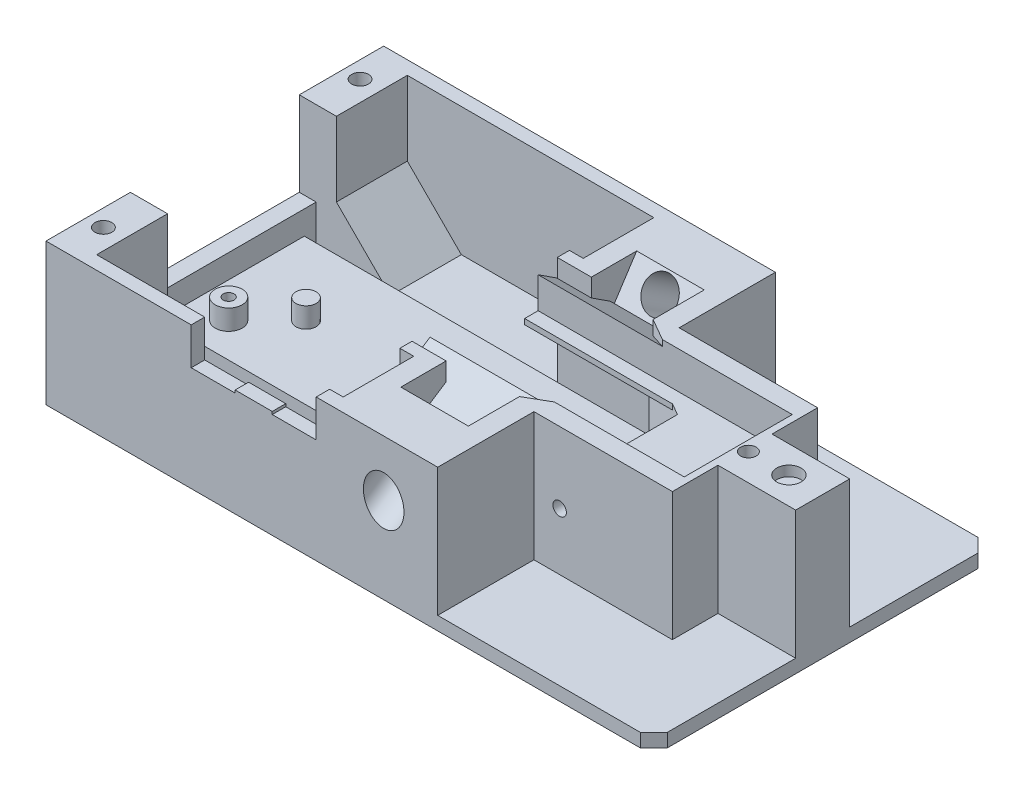
from build123d import *

# Parameters (mm, degrees)
SKETCH1_W           = 90
SKETCH1_H           = 50
BOSS_EXTRUDE1_DEPTH = 21
CUT_EXTRUDE1_DEPTH  = 16
SKETCH4_R           = 2.5
CUT_EXTRUDE2_DEPTH  = 63.626624678
SKETCH5_W           = 10
SKETCH5_H           = 6.2
CUT_EXTRUDE3_DEPTH  = 19
SKETCH6_R           = 3
CUT_EXTRUDE4_DEPTH  = 20
SKETCH11_R          = 1.5
BOSS_EXTRUDE3_DEPTH = 3
BOSS_EXTRUDE2_DEPTH = 23.630686795
CUT_EXTRUDE6_DEPTH  = 19
SKETCH17_W          = 16
SKETCH17_H          = 3.2
CUT_EXTRUDE10_DEPTH = 37.549476
SKETCH15_R          = 1.8
CUT_EXTRUDE8_DEPTH  = 1.5
SKETCH16_R          = 1.25
CUT_EXTRUDE9_DEPTH  = 19
CUT_EXTRUDE11_REACH = 23
SKETCH19_R          = 4
CHAMFER1_SIZE       = 8
CHAMFER2_SIZE       = 2
CUT_EXTRUDE12_REACH = 52
SKETCH21_W          = 21.5
SKETCH21_H          = 3
BOSS_EXTRUDE4_DEPTH = 5.5
CUT_EXTRUDE13_REACH = 23
SKETCH23_W          = 37.630686795
SKETCH23_H          = 16
SKETCH25_R          = 1.15
CUT_EXTRUDE14_DEPTH = 10
SKETCH26_R          = 1
CUT_EXTRUDE15_DEPTH = 36.75
SKETCH27_W          = 2.5
SKETCH27_H          = 25
BOSS_EXTRUDE6_DEPTH = 6.5
SKETCH28_W          = 10
SKETCH28_H          = 0.8
CUT_EXTRUDE16_DEPTH = 4
SKETCH22_R          = 2
SKETCH22_R_2        = 0.8
BOSS_EXTRUDE7_DEPTH = 3


with BuildPart() as part:
    # Sketch1 → Boss-Extrude1 (new body)
    with BuildSketch(Plane(origin=(0, 0, 0), x_dir=(1, 0, 0), z_dir=(0, 1, 0))):
        with Locations((-5, 0)):
            Rectangle(SKETCH1_W, SKETCH1_H)
    extrude(amount=BOSS_EXTRUDE1_DEPTH)

    # Sketch2 → Cut-Extrude1 (cut)
    with BuildSketch(Plane(origin=(0, 21, 0), x_dir=(1, 0, 0), z_dir=(0, 1, 0))):
        Polygon((-44.5, 10.75), (3.5, 10.75), (13.5, 5), (13.5, -5), (3.5, -10.75), (-44.5, -10.75), align=None)
    extrude(amount=-CUT_EXTRUDE1_DEPTH, mode=Mode.SUBTRACT)

    # Sketch4 → Cut-Extrude2 (cut, through all)
    with BuildSketch(Plane(origin=(0, 3.891653574, -38.585684316), x_dir=(1, 0, 0), z_dir=(0, 0.545410535, 0.838169045))):
        Circle(SKETCH4_R)
    cut_extrude2 = extrude(amount=CUT_EXTRUDE2_DEPTH, mode=Mode.SUBTRACT)

    # Sketch5 → Cut-Extrude3 (cut)
    with BuildSketch(Plane(origin=(0, 29, 0), x_dir=(1, 0, 0), z_dir=(0, 0.545410535, 0.838169045))):
        with Locations((0, 0.013708289)):
            Rectangle(SKETCH5_W, SKETCH5_H)
    cut_extrude3 = extrude(amount=-CUT_EXTRUDE3_DEPTH, mode=Mode.SUBTRACT)

    # Sketch6 → Cut-Extrude4 (cut)
    with BuildSketch(Plane(origin=(0, 3.891653574, -38.585684316), x_dir=(1, 0, 0), z_dir=(0, 0.545410535, 0.838169045))):
        Circle(SKETCH6_R)
    cut_extrude4 = extrude(amount=CUT_EXTRUDE4_DEPTH, mode=Mode.SUBTRACT)

    # Sketch11 → Boss-Extrude3 (add)
    with BuildSketch(Plane(origin=(0, 5, 0), x_dir=(1, 0, 0), z_dir=(0, 1, 0))):
        with Locations((-36.5, 0)):
            Circle(SKETCH11_R)
        Polygon((11.3, 6.265), (11.3, -6.265), (13.5, -5), (13.5, 5), align=None)
    extrude(amount=BOSS_EXTRUDE3_DEPTH)

    # Sketch9 → Boss-Extrude2 (add)
    with BuildSketch(Plane.ZY.offset(-13.5)):
        Polygon((-8, 18.7), (-8, 15.5), (-6, 15.5), (-6, 14.7), (-10.75, 13.6), (-11.152370245, 13.6), (-11.152370245, 14.662668332), (-11.152370245, 18.060784345), (-6.635479906, 21), (0, 21), (0, 18.7), align=None)
    boss_extrude2 = extrude(amount=BOSS_EXTRUDE2_DEPTH)

    # Mirror1: Cut-Extrude2, Cut-Extrude3, Cut-Extrude4, Boss-Extrude2 across plane
    add(cut_extrude2.mirror(Plane.XY), mode=Mode.SUBTRACT)
    add(cut_extrude3.mirror(Plane.XY), mode=Mode.SUBTRACT)
    add(cut_extrude4.mirror(Plane.XY), mode=Mode.SUBTRACT)
    add(boss_extrude2.mirror(Plane.XY))

    # Sketch10 → Cut-Extrude6 (cut)
    with BuildSketch(Plane(origin=(0, 21, 0), x_dir=(1, 0, 0), z_dir=(0, 1, 0))):
        Polygon((-44.5, 12.5), (-44.5, 23), (-8, 23), (-8, 12.55), (-10.049475977, 12.55), (-10.049475977, 10.75), (-44.5, 10.75), (-44.5, 0), (-50, 0), (-50, 12.5), align=None)
        Polygon((8, 25), (8, 10.75), (28.5, 10.75), (28.5, 4), (46.328078386, 4), (46.328078386, 30.717572765), (8, 31.044325351), align=None)
    cut_extrude6 = extrude(amount=-CUT_EXTRUDE6_DEPTH, mode=Mode.SUBTRACT)

    # Mirror2: Cut-Extrude6 across plane
    add(cut_extrude6.mirror(Plane.XY), mode=Mode.SUBTRACT)

    # Sketch17 → Cut-Extrude10 (cut)
    with BuildSketch(Plane.ZY.offset(10.049475977)):
        with Locations((0, 17.1)):
            Rectangle(SKETCH17_W, SKETCH17_H)
    extrude(amount=-CUT_EXTRUDE10_DEPTH, mode=Mode.SUBTRACT)

    # Sketch15 → Cut-Extrude8 (cut)
    with BuildSketch(Plane(origin=(0, 21, 0), x_dir=(1, 0, 0), z_dir=(0, 1, 0))):
        with Locations((35, 0)):
            Circle(SKETCH15_R)
    extrude(amount=-CUT_EXTRUDE8_DEPTH, mode=Mode.SUBTRACT)

    # Sketch16 → Cut-Extrude9 (cut)
    with BuildSketch(Plane(origin=(0, 21, 0), x_dir=(1, 0, 0), z_dir=(0, 1, 0))):
        with Locations((-47.5, 19)):
            Circle(SKETCH16_R)
        with Locations((-47.5, -19)):
            Circle(SKETCH16_R)
    extrude(amount=-CUT_EXTRUDE9_DEPTH, mode=Mode.SUBTRACT)

    # Sketch19 → Cut-Extrude11 (cut, up to next)
    with BuildSketch(Plane(origin=(0, 21, 0), x_dir=(1, 0, 0), z_dir=(0, 1, 0)), mode=Mode.PRIVATE) as cut_extrude11_sk1:
        Circle(SKETCH19_R)
    cut_extrude11_tool1 = extrude(cut_extrude11_sk1.sketch, amount=-CUT_EXTRUDE11_REACH, mode=Mode.PRIVATE) & part.part
    add(cut_extrude11_tool1.solids().sort_by_distance((0, 21, 0))[0], mode=Mode.SUBTRACT)

    # Chamfer1
    chamfer1_edges = [part.edges().sort_by_distance(p)[0] for p in [
        (-44.5, 2, -17.75),
        (-44.5, 2, 17.75),
    ]]
    chamfer(chamfer1_edges, length=CHAMFER1_SIZE)

    # Chamfer2
    chamfer2_edges = [part.edges().sort_by_distance(p)[0] for p in [
        (40, 1, -25),
        (40, 1, 25),
    ]]
    chamfer(chamfer2_edges, length=CHAMFER2_SIZE)

    # Sketch20 → Cut-Extrude12 (cut, up to next)
    with BuildSketch(Plane.XY.offset(25), mode=Mode.PRIVATE) as cut_extrude12_sk1:
        Polygon((-28.5, 15.5), (-22, 15.5), (-22, 15.9), (-16.5, 15.9), (-16.5, 15.5), (-10, 15.5), (-10, 21), (-28.5, 21), (-28.5, 15.8), align=None)
    cut_extrude12_tool1 = extrude(cut_extrude12_sk1.sketch, amount=-CUT_EXTRUDE12_REACH, mode=Mode.PRIVATE) & part.part
    add(cut_extrude12_tool1.solids().sort_by_distance((-19.25, 18.306354, 25))[0], mode=Mode.SUBTRACT)

    # Sketch21 → Boss-Extrude4 (add)
    with BuildSketch(Plane.ZY.offset(44.5)):
        with Locations((0, 3.5)):
            Rectangle(SKETCH21_W, SKETCH21_H)
    extrude(amount=BOSS_EXTRUDE4_DEPTH)

    # Sketch23 → Cut-Extrude13 (cut, up to next)
    with BuildSketch(Plane(origin=(0, 21, 0), x_dir=(1, 0, 0), z_dir=(0, 1, 0)), mode=Mode.PRIVATE) as cut_extrude13_sk1:
        with Locations((8.684656602, 0)):
            Rectangle(SKETCH23_W, SKETCH23_H)
    cut_extrude13_tool1 = extrude(cut_extrude13_sk1.sketch, amount=-CUT_EXTRUDE13_REACH, mode=Mode.PRIVATE) & part.part
    add(cut_extrude13_tool1.solids().sort_by_distance((8.684657, 21, 0))[0], mode=Mode.SUBTRACT)

    # Sketch25 → Cut-Extrude14 (cut)
    with BuildSketch(Plane(origin=(0, 21, 0), x_dir=(1, 0, 0), z_dir=(0, 1, 0))):
        with Locations((29, 0)):
            Circle(SKETCH25_R)
    extrude(amount=-CUT_EXTRUDE14_DEPTH, mode=Mode.SUBTRACT)

    # Sketch26 → Cut-Extrude15 (cut, through all)
    with BuildSketch(Plane.XY.offset(10.75)):
        with Locations((11.80251356, 10.471486046)):
            Circle(SKETCH26_R)
    extrude(amount=-CUT_EXTRUDE15_DEPTH, mode=Mode.SUBTRACT)

    # Sketch27 → Boss-Extrude6 (add)
    with BuildSketch(Plane(origin=(0, 2, 0), x_dir=(1, 0, 0), z_dir=(0, 1, 0))):
        with Locations((-48.75, 0)):
            Rectangle(SKETCH27_W, SKETCH27_H)
    extrude(amount=BOSS_EXTRUDE6_DEPTH)

    # Sketch28 → Cut-Extrude16 (cut)
    with BuildSketch(Plane(origin=(0, 17.786458912, 11.573944585), x_dir=(1, 0, 0), z_dir=(0, 0.838169045, 0.545410535))):
        with Locations((0, -2.783094473)):
            Rectangle(SKETCH28_W, SKETCH28_H)
    cut_extrude16 = extrude(amount=-CUT_EXTRUDE16_DEPTH, mode=Mode.SUBTRACT)

    # Mirror3: Cut-Extrude16 across plane
    add(cut_extrude16.mirror(Plane.XY), mode=Mode.SUBTRACT)

    # Sketch22 → Boss-Extrude7 (add)
    with BuildSketch(Plane(origin=(0, 5, 0), x_dir=(1, 0, 0), z_dir=(0, 1, 0))):
        with Locations((-42.3, -5.65)):
            Circle(SKETCH22_R)
        with Locations((-42.3, -5.65)):
            Circle(SKETCH22_R_2, mode=Mode.SUBTRACT)
        with Locations((9.66, 4.95)):
            Circle(SKETCH22_R)
        with Locations((9.66, 4.95)):
            Circle(SKETCH22_R_2, mode=Mode.SUBTRACT)
    extrude(amount=BOSS_EXTRUDE7_DEPTH)


solid = part.part
